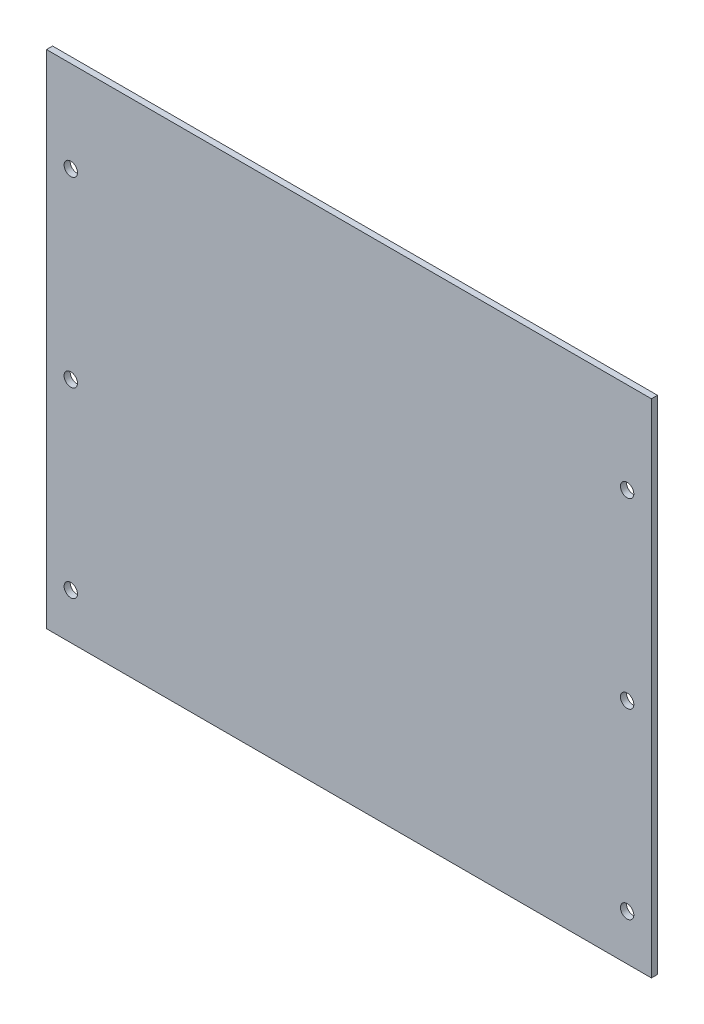
from build123d import *

# Parameters (mm, degrees)
SKETCH_1_W          = 199
SKETCH_1_H          = 165
EXTRUDE_1_DEPTH     = 2
SKETCH_2_R          = 2.2
CUT_EXTRUDE_1_DEPTH = 2
SKETCH_3_R          = 2.2
CUT_EXTRUDE_2_DEPTH = 2


with BuildPart() as part:
    # ｽｹｯﾁ1 → ﾎﾞｽ - 押し出し1 (new body)
    with BuildSketch(Plane.XY):
        Rectangle(SKETCH_1_W, SKETCH_1_H)
    extrude(amount=EXTRUDE_1_DEPTH)

    # ｽｹｯﾁ2 → ｶｯﾄ - 押し出し1 (cut)
    with BuildSketch(Plane.XY.offset(2)):
        with Locations((-91.5, -67.5)):
            Circle(SKETCH_2_R)
        with Locations((-91.5, -7.5)):
            Circle(SKETCH_2_R)
        with Locations((-91.5, 52.5)):
            Circle(SKETCH_2_R)
    extrude(amount=-CUT_EXTRUDE_1_DEPTH, mode=Mode.SUBTRACT)

    # ｽｹｯﾁ3 → ｶｯﾄ - 押し出し2 (cut)
    with BuildSketch(Plane.XY.offset(2)):
        with Locations((91.5, -67.5)):
            Circle(SKETCH_3_R)
        with Locations((91.5, -7.5)):
            Circle(SKETCH_3_R)
        with Locations((91.5, 52.5)):
            Circle(SKETCH_3_R)
    extrude(amount=-CUT_EXTRUDE_2_DEPTH, mode=Mode.SUBTRACT)


solid = part.part
